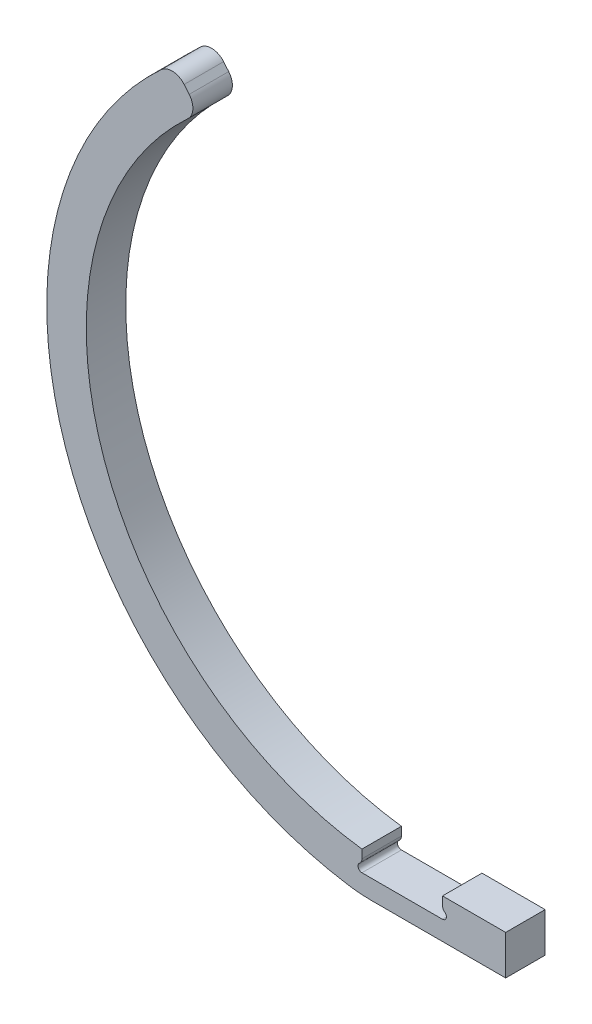
from build123d import *

# Parameters (mm, degrees)
BOSS_EXTRUDE1_DEPTH = 6.35
SKETCH2_R           = 0.635
CUT_EXTRUDE1_DEPTH  = 7.35
FILLET2_R           = 1.016
FILLET3_R           = 25.4


with BuildPart() as part:
    # Sketch1 → Boss-Extrude1 (new body)
    with BuildSketch(Plane.XY):
        with BuildLine():
            ThreePointArc((-38.731808071, 42.023440406), (-54.328419489, -17.735426012), (-6.477, -56.781783796))
            Line((-6.477, -56.781783796), (6.477, -56.781783796))
            Line((6.477, -56.781783796), (16.637, -56.781783796))
            Line((16.637, -56.781783796), (16.637, -50.431783796))
            Line((16.637, -50.431783796), (6.477, -50.431783796))
            Line((6.477, -50.431783796), (6.477, -53.682983796))
            Line((6.477, -53.682983796), (-6.477, -53.682983796))
            Line((-6.477, -53.682983796), (-6.477, -50.385399383))
            ThreePointArc((-6.477, -50.385399383), (-48.394630123, -15.446675216), (-34.469665313, 37.315977453))
            ThreePointArc((-34.469665313, 37.315977453), (-33.658259426, 39.020726685), (-34.247395693, 40.814456854))
            Line((-34.247395693, 40.814456854), (-35.064641493, 41.788412472))
            ThreePointArc((-35.064641493, 41.788412472), (-36.847939613, 42.690531433), (-38.731808071, 42.023440406))
        make_face()
    extrude(amount=BOSS_EXTRUDE1_DEPTH)

    # Sketch2 → Cut-Extrude1 (cut, through all)
    with BuildSketch(Plane.XY.offset(6.35)):
        with Locations((-6.477, -53.047983796)):
            Circle(SKETCH2_R)
        with Locations((6.477, -53.047983796)):
            Circle(SKETCH2_R)
    extrude(amount=-CUT_EXTRUDE1_DEPTH, mode=Mode.SUBTRACT)

    # Fillet2
    fillet2_edges = [part.edges().sort_by_distance(p)[0] for p in [
        (-6.477, -52.412983796, 3.175),
        (6.477, -52.412983796, 3.175),
    ]]
    fillet(fillet2_edges, radius=FILLET2_R)

    # Fillet3
    fillet3_edges = [part.edges().sort_by_distance(p)[0] for p in [
        (-6.477, -56.781783796, 3.175),
    ]]
    fillet(fillet3_edges, radius=FILLET3_R)


solid = part.part
